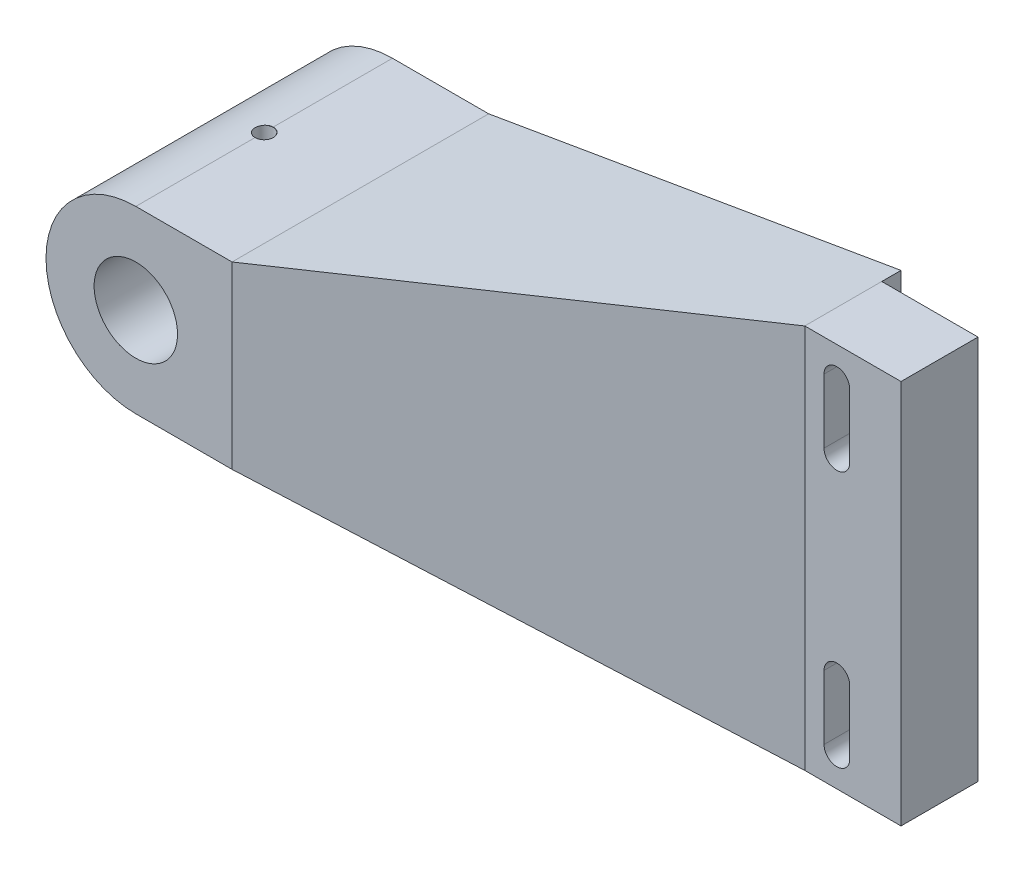
from build123d import *

# Parameters (mm, degrees)
SKETCH_1_R                        = 6.5
EXTRUDE_1_DEPTH                   = 40
SKETCH_2_W                        = 15
SKETCH_2_H                        = 60
SKETCH_3_W                        = 12
SKETCH_3_H                        = 60
EXTRUDE_2_DEPTH                   = 15
CUT_EXTRUDE_1_DEPTH               = 21.0000001
HOLE_WIZARD_2_8_2_8_1_D           = 2.8
HOLE_WIZARD_2_8_2_8_1_CSINK_D     = 2.85
HOLE_WIZARD_2_8_2_8_1_CSINK_ANGLE = 90


with BuildPart() as part:
    # 草圖1 → 填料-伸長1 (new body)
    with BuildSketch(Plane.XY):
        with BuildLine():
            Line((15, 14), (0, 14))
            ThreePointArc((0, 14), (-14, 0), (0, -14))
            Line((0, -14), (15, -14))
            Line((15, -14), (15, 14))
        make_face()
        Circle(SKETCH_1_R, mode=Mode.SUBTRACT)
    extrude(amount=EXTRUDE_1_DEPTH)

    # 草圖2 → section 1 of loft_1
    with BuildSketch(Plane(origin=(84.27, 0, 0), x_dir=(0, 0, -1), z_dir=(1, 0, 0)), mode=Mode.PRIVATE) as loft_1_s1:
        with Locations((-12.5, 0)):
            Rectangle(SKETCH_2_W, SKETCH_2_H)
    # loft from a face of the part (loft_1)
    loft([part.faces().sort_by_distance((15, 0, 20))[0], loft_1_s1.sketch])

    # 草圖3 → 填料-伸長2 (add)
    with BuildSketch(Plane(origin=(84.27, 0, 0), x_dir=(0, 0, -1), z_dir=(1, 0, 0))):
        with Locations((-14, 0)):
            Rectangle(SKETCH_3_W, SKETCH_3_H)
    extrude(amount=EXTRUDE_2_DEPTH)

    # 草圖4 → 除料-伸長1 (cut, through all)
    with BuildSketch(Plane.XY.offset(20)):
        with BuildLine():
            Line((91.27, 25), (91.27, 15))
            ThreePointArc((91.27, 15), (89.27, 13), (87.27, 15))
            Line((87.27, 15), (87.27, 25))
            ThreePointArc((87.27, 25), (89.27, 27), (91.27, 25))
        make_face()
        with BuildLine():
            Line((91.27, -15), (91.27, -25))
            ThreePointArc((91.27, -25), (89.27, -27), (87.27, -25))
            Line((87.27, -25), (87.27, -15))
            ThreePointArc((87.27, -15), (89.27, -13), (91.27, -15))
        make_face()
    extrude(amount=-CUT_EXTRUDE_1_DEPTH, mode=Mode.SUBTRACT)

    # Ø2.8 (2.8) 直徑孔1 (through all)
    with Locations(Plane(origin=(0, 14, 0), x_dir=(1, 0, 0), z_dir=(0, 1, 0))):
        with Locations((0, -20)):
            CounterSinkHole(HOLE_WIZARD_2_8_2_8_1_D / 2, HOLE_WIZARD_2_8_2_8_1_CSINK_D / 2, counter_sink_angle=HOLE_WIZARD_2_8_2_8_1_CSINK_ANGLE)


solid = part.part
